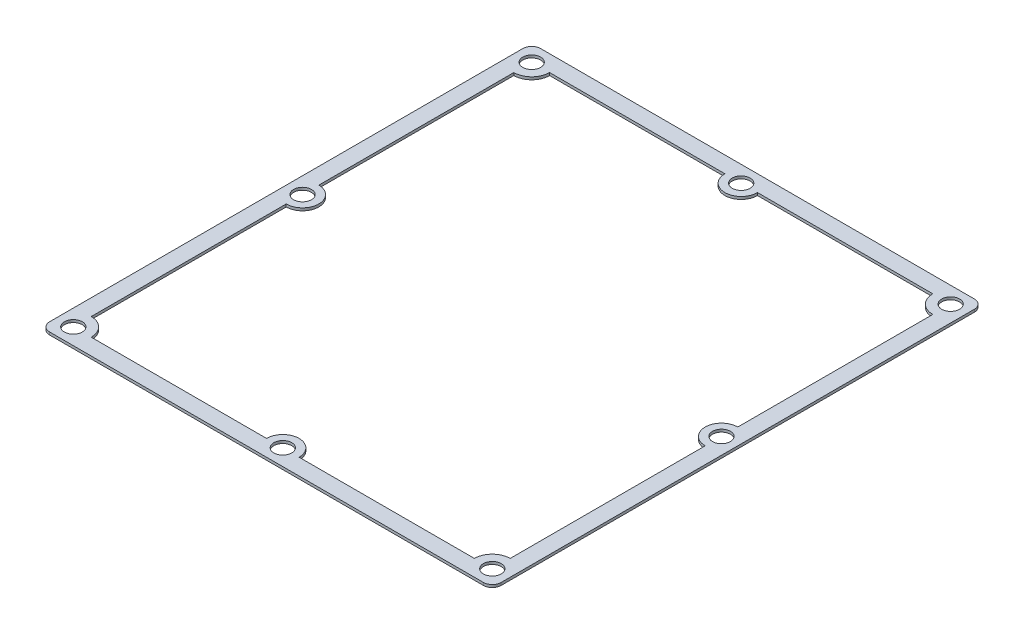
from build123d import *

# Parameters (mm, degrees)
SKETCH_1_R      = 1.7
EXTRUDE_1_DEPTH = 0.5


with BuildPart() as part:
    # Эскиз1 → Бобышка-Вытянуть1 (new body)
    with BuildSketch(Plane(origin=(0, 0, 0), x_dir=(1, 0, 0), z_dir=(0, 1, 0))):
        with BuildLine():
            Line((-40.771031168, -46.911249121), (41.728968832, -46.911249121))
            ThreePointArc((41.728968832, -46.911249121), (42.93105036, -46.413330649), (43.428968832, -45.211249121))
            Line((43.428968832, -45.211249121), (43.428968832, 44.788750879))
            ThreePointArc((43.428968832, 44.788750879), (42.93105036, 45.990832407), (41.728968832, 46.488750879))
            Line((41.728968832, 46.488750879), (-40.771031168, 46.488750879))
            ThreePointArc((-40.771031168, 46.488750879), (-41.973112696, 45.990832407), (-42.471031168, 44.788750879))
            Line((-42.471031168, 44.788750879), (-42.471031168, -45.211249121))
            ThreePointArc((-42.471031168, -45.211249121), (-41.973112696, -46.413330649), (-40.771031168, -46.911249121))
        make_face()
        with Locations((-39.371031168, -0.211249121)):
            Circle(SKETCH_1_R, mode=Mode.SUBTRACT)
        with Locations((-39.371031168, -43.811249121)):
            Circle(SKETCH_1_R, mode=Mode.SUBTRACT)
        with Locations((0.478968832, -43.811249121)):
            Circle(SKETCH_1_R, mode=Mode.SUBTRACT)
        with Locations((40.328968832, -43.811249121)):
            Circle(SKETCH_1_R, mode=Mode.SUBTRACT)
        with Locations((40.328968832, -0.211249121)):
            Circle(SKETCH_1_R, mode=Mode.SUBTRACT)
        with Locations((40.328968832, 43.388750879)):
            Circle(SKETCH_1_R, mode=Mode.SUBTRACT)
        with Locations((0.478968832, 43.388750879)):
            Circle(SKETCH_1_R, mode=Mode.SUBTRACT)
        with Locations((-39.371031168, 43.388750879)):
            Circle(SKETCH_1_R, mode=Mode.SUBTRACT)
        with BuildLine():
            Line((-39.371031168, 39.987280609), (-39.371031168, 2.888750879))
            ThreePointArc((-39.371031168, 2.888750879), (-36.271031168, -0.211249121), (-39.371031168, -3.311249121))
            Line((-39.371031168, -3.311249121), (-39.371031168, -40.40977885))
            ThreePointArc((-39.371031168, -40.40977885), (-36.965828473, -41.406046427), (-35.969560897, -43.811249121))
            Line((-35.969560897, -43.811249121), (-2.621031168, -43.811249121))
            ThreePointArc((-2.621031168, -43.811249121), (0.478968832, -40.711249121), (3.578968832, -43.811249121))
            Line((3.578968832, -43.811249121), (36.927498562, -43.811249121))
            ThreePointArc((36.927498562, -43.811249121), (37.923766138, -41.406046427), (40.328968832, -40.40977885))
            Line((40.328968832, -40.40977885), (40.328968832, -3.311249121))
            ThreePointArc((40.328968832, -3.311249121), (37.228968832, -0.211249121), (40.328968832, 2.888750879))
            Line((40.328968832, 2.888750879), (40.328968832, 39.987280609))
            ThreePointArc((40.328968832, 39.987280609), (37.923766138, 40.983548185), (36.927498562, 43.388750879))
            Line((36.927498562, 43.388750879), (3.578968832, 43.388750879))
            ThreePointArc((3.578968832, 43.388750879), (0.478968832, 40.288750879), (-2.621031168, 43.388750879))
            Line((-2.621031168, 43.388750879), (-35.969560897, 43.388750879))
            ThreePointArc((-35.969560897, 43.388750879), (-36.965828473, 40.983548185), (-39.371031168, 39.987280609))
        make_face(mode=Mode.SUBTRACT)
    extrude(amount=EXTRUDE_1_DEPTH)


solid = part.part
